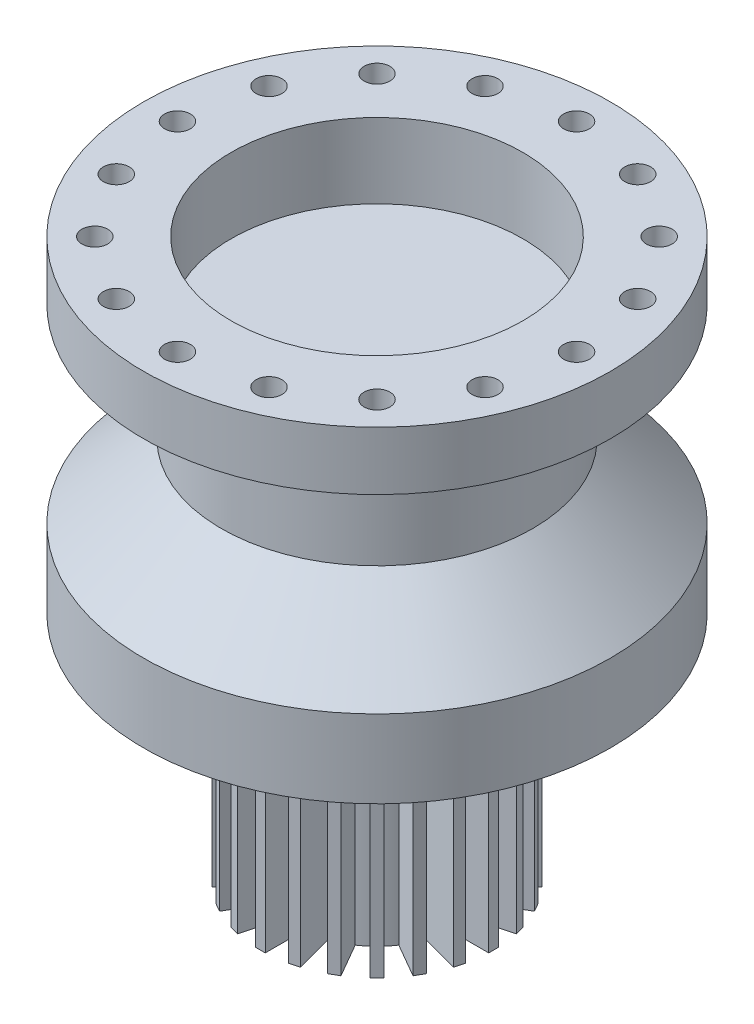
from build123d import *

# Parameters (mm, degrees)
SKETCH2_W                    = 3.175
SKETCH2_H                    = 12.7
BOSS_EXTRUDE1_DEPTH          = 76.2
CIRPATTERN1_COUNT            = 24
F_5_16_CLEARANCE_HOLE1_D     = 8.4328
F_5_16_CLEARANCE_HOLE1_DEPTH = 19.05
CIRPATTERN2_COUNT            = 16


with BuildPart() as part:
    # Sketch1 → Revolve1 (revolve)
    with BuildSketch(Plane.XY):
        Polygon((47.625, 0), (76.2, 0), (76.2, -19.05), (50.8, -19.05), (50.8, -57.15), (76.2, -81.053060455), (76.2, -106.453060455), (25.4, -106.453060455), (25.4, -182.653060455), (0, -182.653060455), (0, -24.40228768), (47.625, -24.40228768), align=None)
    revolve(axis=Axis((0, -1509.759665614, 0), (0, 1, 0)))

    # Sketch2 → Boss-Extrude1 (add)
    with BuildSketch(Plane.XZ.offset(106.453060455)):
        with Locations((0, 31.700342083)):
            Rectangle(SKETCH2_W, SKETCH2_H)
    boss_extrude1 = extrude(amount=BOSS_EXTRUDE1_DEPTH)

    # CirPattern1: Boss-Extrude1 ×24 about axis
    cirpattern1_axis = Axis((0, 0, 0), (0, 1, 0))
    for i in range(1, CIRPATTERN1_COUNT):
        add(boss_extrude1.rotate(cirpattern1_axis, i * 360 / CIRPATTERN1_COUNT))

    # 5/16 Clearance Hole1
    with Locations(Plane(origin=(0, 0, 0), x_dir=(1, 0, 0), z_dir=(0, 1, 0))):
        with Locations((0, 65.1256)):
            f_5_16_clearance_hole1 = Hole(F_5_16_CLEARANCE_HOLE1_D / 2, depth=F_5_16_CLEARANCE_HOLE1_DEPTH)

    # CirPattern2: 5/16 Clearance Hole1 ×16 about axis
    cirpattern2_axis = Axis((0, 0, 0), (0, 1, 0))
    for i in range(1, CIRPATTERN2_COUNT):
        add(f_5_16_clearance_hole1.rotate(cirpattern2_axis, i * 360 / CIRPATTERN2_COUNT), mode=Mode.SUBTRACT)


solid = part.part
